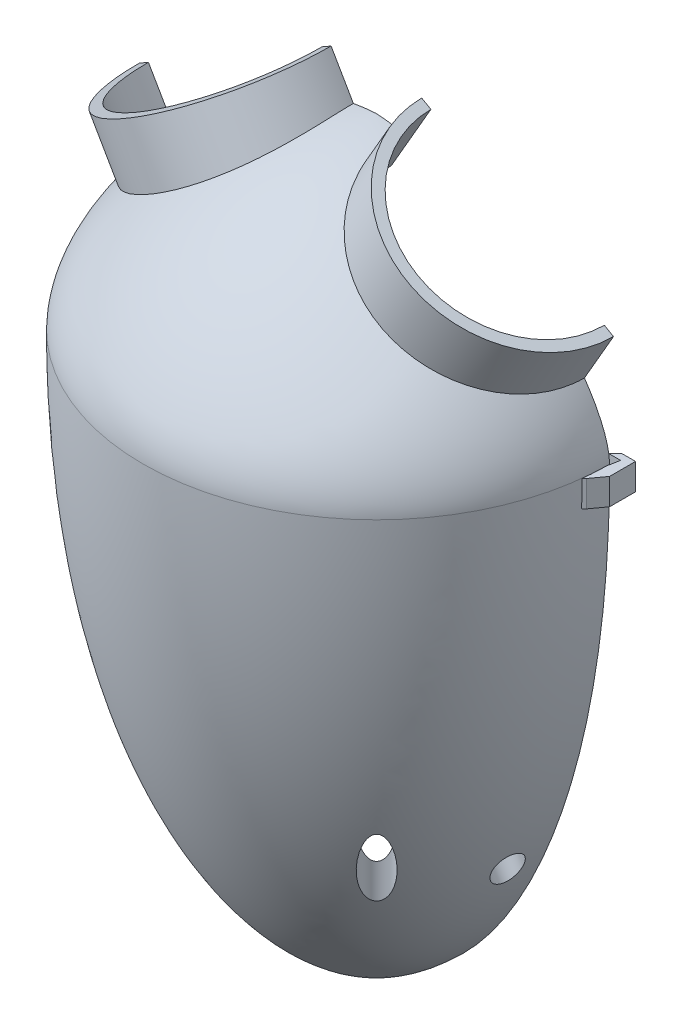
from build123d import *

# Parameters (mm, degrees)
SKETCH11_R              = 21.025
BOSS_EXTRUDE1_DEPTH     = 15
CUT_EXTRUDE1_DEPTH      = 15
CUT_EXTRUDE1_DEPTH_BACK = 15
SKETCH10_R              = 19.025
SKETCH9_R               = 21.025
BOSS_EXTRUDE2_DEPTH     = 15
CUT_EXTRUDE2_DEPTH      = 15
CUT_EXTRUDE2_DEPTH_BACK = 15
SKETCH8_R               = 19.025
SKETCH12_W              = 99.794002181
SKETCH12_H              = 155.914942097
CUT_EXTRUDE4_DEPTH      = 121.569943142
BOSS_EXTRUDE3_DEPTH     = 5
SKETCH15_R              = 2.75
CUT_EXTRUDE5_DEPTH      = 122.015670326
CIRPATTERN1_COUNT       = 4
CUT_EXTRUDE6_DEPTH      = 146.40293202
CUT_EXTRUDE6_DEPTH_BACK = 111
SKETCH18_R              = 2.75
SKETCH16_R              = 2.75
CUT_EXTRUDE7_DEPTH      = 111


with BuildPart() as part:
    # Sketch1 → Revolve1 (revolve)
    with BuildSketch(Plane.XY):
        with BuildLine():
            Line((-0.054587449, 35.519508176), (-0.054587449, 32.519508176))
            add(Edge.make_bspline(
                [(41.245412551, 0.019508176), (40.958337014, 9.014928546), (18.606901034, 32.079858268), (-0.054587449, 32.519508176)],
                knots=[0, 0, 0, 0, 1, 1, 1, 1], degree=3))
            add(Edge.make_bspline(
                [(41.245412551, 0.019508176), (41.577918041, -63.31295231), (18.687364585, -99.514781639), (-0.054587449, -99.680491824)],
                knots=[0, 0, 0, 0, 1, 1, 1, 1], degree=3))
            Line((-0.054587449, -99.680491824), (-0.054587449, -102.680491824))
            add(Edge.make_bspline(
                [(44.245412551, 0.019508176), (44.245412551, -67.798568914), (17.945412551, -102.680491824), (-0.054587449, -102.680491824)],
                knots=[0, 0, 0, 0, 1, 1, 1, 1], degree=3))
            add(Edge.make_bspline(
                [(44.245412551, 0.019508176), (43.885165552, 12.34757912), (21.905581412, 34.196260806), (-0.054587449, 35.519508176)],
                knots=[0, 0, 0, 0, 1, 1, 1, 1], degree=3))
        make_face()
    revolve(axis=Axis((-0.054587449, 0.019508176, 0), (0, -1, 0)))

    # Sketch11 → Boss-Extrude1 (add)
    with BuildSketch(Plane(origin=(12.990381057, 22.5, 0), x_dir=(0, 0, -1), z_dir=(0.500000000000001, 0.866025403784438, 0))):
        with Locations((0, -7.252971794)):
            Circle(SKETCH11_R)
    extrude(amount=BOSS_EXTRUDE1_DEPTH)

    # Sketch10 → Cut-Extrude1 (cut, two sides: drawn at the far end of the back side and taken through both)
    with BuildSketch(Plane(origin=(12.990381057, 22.5, 0), x_dir=(0, 0, -1), z_dir=(0.500000000000001, 0.866025403784438, 0)).offset(-CUT_EXTRUDE1_DEPTH_BACK)):
        with Locations((0, -7.252971794)):
            Circle(SKETCH10_R)
    extrude(amount=CUT_EXTRUDE1_DEPTH + CUT_EXTRUDE1_DEPTH_BACK, mode=Mode.SUBTRACT)

    # Sketch9 → Boss-Extrude2 (add)
    with BuildSketch(Plane(origin=(-12.990381057, 22.5, 0), x_dir=(0, 0, -1), z_dir=(-0.4999999999999889, 0.866025403784445, 0))):
        with Locations((0, 7.35752003)):
            Circle(SKETCH9_R)
    extrude(amount=BOSS_EXTRUDE2_DEPTH)

    # Sketch8 → Cut-Extrude2 (cut, two sides: drawn at the far end of the back side and taken through both)
    with BuildSketch(Plane(origin=(-12.990381057, 22.5, 0), x_dir=(0, 0, -1), z_dir=(-0.4999999999999889, 0.866025403784445, 0)).offset(-CUT_EXTRUDE2_DEPTH_BACK)):
        with Locations((0, 7.35752003)):
            Circle(SKETCH8_R)
    extrude(amount=CUT_EXTRUDE2_DEPTH + CUT_EXTRUDE2_DEPTH_BACK, mode=Mode.SUBTRACT)

    # Sketch12 → Cut-Extrude4 (cut, through all)
    with BuildSketch(Plane.XY):
        with Locations((-0.467232668, -26.186748073)):
            Rectangle(SKETCH12_W, SKETCH12_H)
    extrude(amount=-CUT_EXTRUDE4_DEPTH, mode=Mode.SUBTRACT)

    # Sketch13 → Boss-Extrude3 (add)
    with BuildSketch(Plane(origin=(0, 0, 0), x_dir=(1, 0, 0), z_dir=(0, 1, 0))):
        Polygon((-46.249529992, -2.005664315), (-46.249529992, 2.911939182), (-43.731448202, 2.911939182), (-42.382312553, 1.666583198), (-44.646857809, 1.666583198), (-44.354587449, 0), (-42.876054968, -5.891558327), (-44.388216305, -4.575771399), align=None)
    boss_extrude3 = extrude(amount=-BOSS_EXTRUDE3_DEPTH)

    # Mirror1: Boss-Extrude3 across plane
    add(boss_extrude3.mirror(Plane(origin=(0, 0, 0), x_dir=(0, 0, 1), z_dir=(1, 0, 0))))

    # Sketch15 → Cut-Extrude5 (cut, through all)
    with BuildSketch(Plane(origin=(0, 0, 0), x_dir=(1, 0, 0), z_dir=(0, 1, 0))):
        with Locations((-24.05, -24.05)):
            Circle(SKETCH15_R)
    cut_extrude5 = extrude(amount=-CUT_EXTRUDE5_DEPTH, mode=Mode.SUBTRACT)

    # CirPattern1: Cut-Extrude5 ×4 about axis
    cirpattern1_axis = Axis((-0.054587449, 0.019508176, 0), (0, 1, 0))
    for i in range(1, CIRPATTERN1_COUNT):
        add(cut_extrude5.rotate(cirpattern1_axis, i * 360 / CIRPATTERN1_COUNT), mode=Mode.SUBTRACT)

    # Sketch18 → Cut-Extrude6 (cut, two sides: drawn at the far end of the back side and taken through both)
    with BuildSketch(Plane(origin=(12.990381057, 22.5, 0), x_dir=(0, 0, -1), z_dir=(0.500000000000001, 0.866025403784438, 0)).offset(-CUT_EXTRUDE6_DEPTH_BACK)):
        with Locations((-6.5, -7.68977505)):
            Circle(SKETCH18_R)
    extrude(amount=CUT_EXTRUDE6_DEPTH + CUT_EXTRUDE6_DEPTH_BACK, mode=Mode.SUBTRACT)

    # Sketch16 → Cut-Extrude7 (cut)
    with BuildSketch(Plane(origin=(-12.990381057, 22.5, 0), x_dir=(0, 0, -1), z_dir=(-0.4999999999999889, 0.866025403784445, 0))):
        with Locations((-6.5, 7.666232324)):
            Circle(SKETCH16_R)
    extrude(amount=-CUT_EXTRUDE7_DEPTH, mode=Mode.SUBTRACT)


solid = part.part
